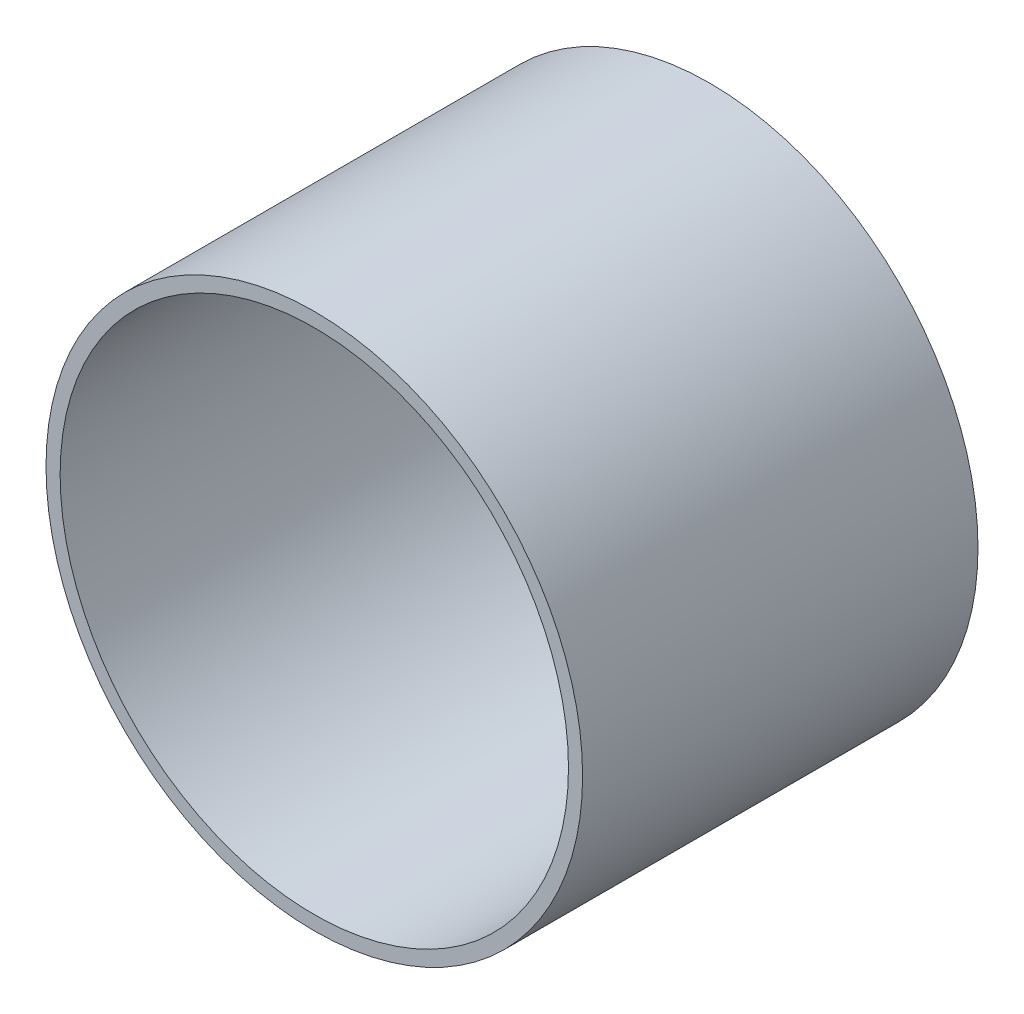
from build123d import *

# Parameters (mm, degrees)
SKETCH1_R           = 9.5
BOSS_EXTRUDE1_DEPTH = 14
SKETCH2_R           = 9
CUT_EXTRUDE1_DEPTH  = 13


with BuildPart() as part:
    # Sketch1 → Boss-Extrude1 (new body)
    with BuildSketch(Plane.XY):
        Circle(SKETCH1_R)
    extrude(amount=BOSS_EXTRUDE1_DEPTH)

    # Sketch2 → Cut-Extrude1 (cut)
    with BuildSketch(Plane.XY.offset(14)):
        Circle(SKETCH2_R)
    extrude(amount=-CUT_EXTRUDE1_DEPTH, mode=Mode.SUBTRACT)


solid = part.part
